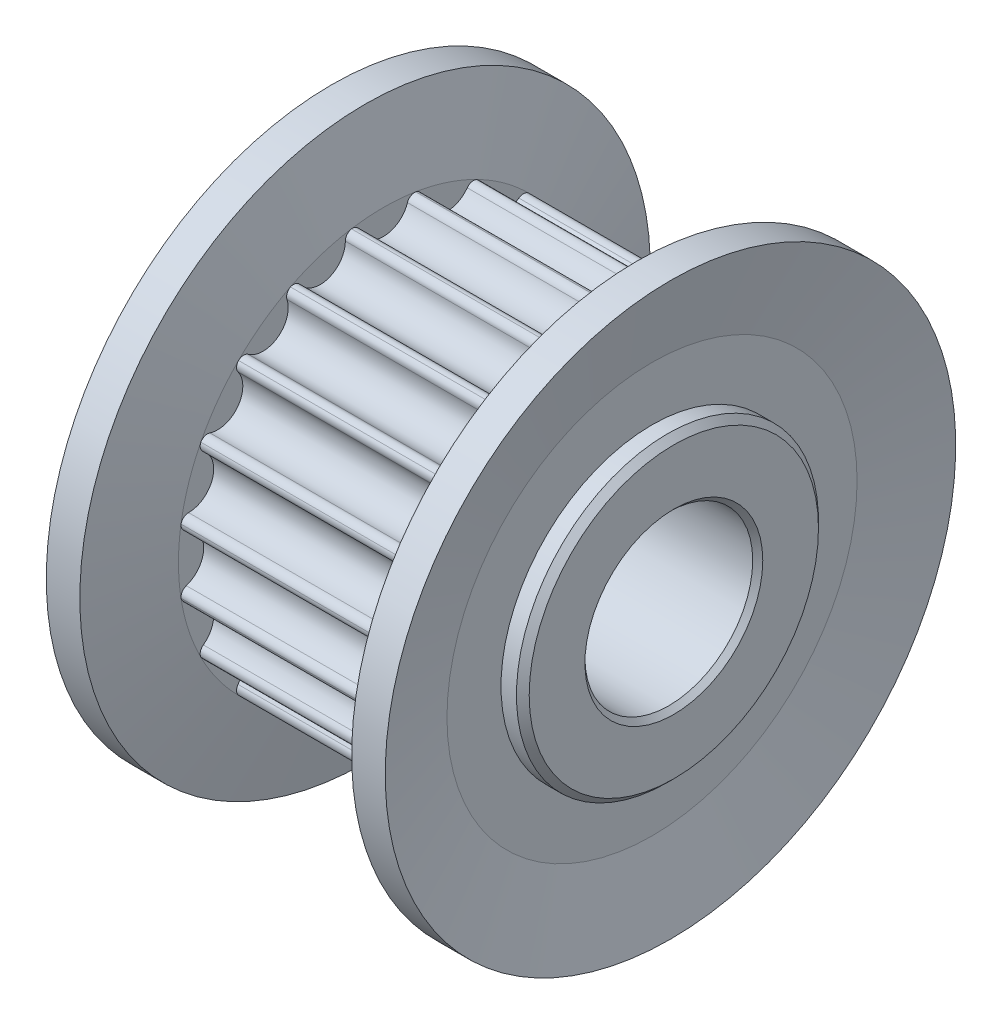
from build123d import *

# Parameters (mm, degrees)
CUT_EXTRUDE_START        = 1.65
CUT_EXTRUDE_1_DEPTH      = 7
PATTERN_CIRCULAR_1_COUNT = 20
SKETCH_6_R               = 2.5
CUT_EXTRUDE_2_DEPTH      = 11.3
CHAMFER_1_SIZE           = 0.15


with BuildPart() as part:
    # Sketch 3 → Revolve 1 (revolve)
    with BuildSketch(Plane.XY):
        Polygon((0, 0), (0, 4.31), (0.19, 4.5), (1.65, 4.5), (1.65, 6.11), (8.65, 6.11), (8.65, 4.5), (10.11, 4.5), (10.3, 4.31), (10.3, 0), align=None)
    revolve(axis=Axis((10.3, 0, 0), (-1, 0, 0)))

    # Sketch 4 → Cut-Extrude 1 (cut)
    with BuildSketch(Plane(origin=(0, 0, 0), x_dir=(0, 0, -1), z_dir=(1, 0, 0)).offset(CUT_EXTRUDE_START)):
        with BuildLine():
            ThreePointArc((0.968009552, 6.032831633), (0.81174441, 6.002056879), (0.712936658, 5.877145279))
            ThreePointArc((0.712936658, 5.877145279), (0, 5.36), (-0.712936658, 5.877145279))
            ThreePointArc((-0.712936658, 5.877145279), (-0.81174441, 6.002056879), (-0.968009552, 6.032831633))
            ThreePointArc((-0.968009552, 6.032831633), (0, 6.11), (0.968009552, 6.032831633))
        make_face()
    cut_extrude_1 = extrude(amount=CUT_EXTRUDE_1_DEPTH, mode=Mode.SUBTRACT)

    # Pattern Circular 1: Cut-Extrude 1 ×20 about axis
    pattern_circular_1_axis = Axis((0, 0, 0), (1, 0, 0))
    for i in range(1, PATTERN_CIRCULAR_1_COUNT):
        add(cut_extrude_1.rotate(pattern_circular_1_axis, i * 360 / PATTERN_CIRCULAR_1_COUNT), mode=Mode.SUBTRACT)

    # Sketch 5 → Revolve 2 (revolve)
    with BuildSketch(Plane.XY):
        Polygon((1.1, 8.5), (1.65, 6.11), (1.65, 4.5), (0.65, 4.5), (0.65, 6.11), (0.1, 8.5), align=None)
        Polygon((9.65, 4.5), (8.65, 4.5), (8.65, 6.11), (9.2, 8.5), (10.2, 8.5), (9.65, 6.11), align=None)
    revolve(axis=Axis((0, 0, 0), (1, 0, 0)))

    # Sketch 6 → Cut-Extrude 2 (cut, through all)
    with BuildSketch(Plane(origin=(0, 0, 0), x_dir=(0, 0, -1), z_dir=(1, 0, 0))):
        Circle(SKETCH_6_R)
    extrude(amount=CUT_EXTRUDE_2_DEPTH, mode=Mode.SUBTRACT)

    # Chamfer 1
    chamfer_1_edges = [part.edges().sort_by_distance(p)[0] for p in [
        (0, 0, 2.5),
        (10.3, 0, 2.5),
    ]]
    chamfer(chamfer_1_edges, length=CHAMFER_1_SIZE)


solid = part.part
